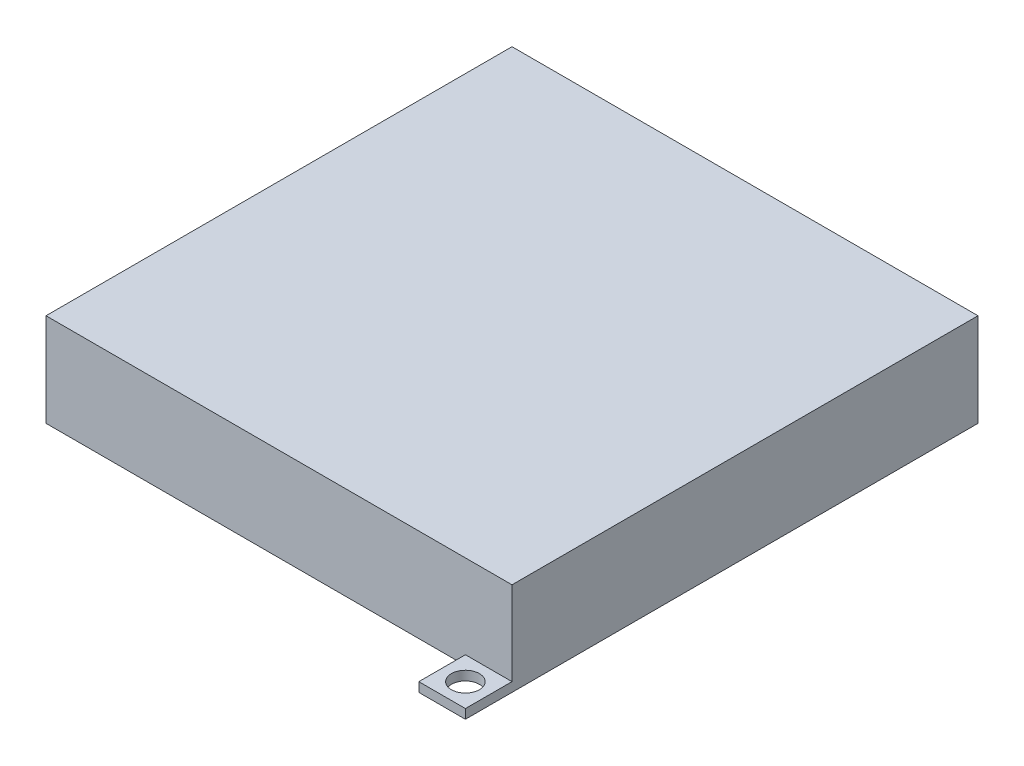
from build123d import *

# Parameters (mm, degrees)
SKETCH4_W           = 50
SKETCH4_H           = 50
BOSS_EXTRUDE1_DEPTH = 10
SKETCH5_W           = 40
SKETCH5_H           = 40
CUT_EXTRUDE1_DEPTH  = 7
SKETCH9_W           = 5
SKETCH9_H           = 5
SKETCH9_R           = 1.5
BOSS_EXTRUDE4_DEPTH = 1


with BuildPart() as part:
    # Sketch4 → Boss-Extrude1 (new body)
    with BuildSketch(Plane(origin=(0, 0, 0), x_dir=(1, 0, 0), z_dir=(0, 1, 0))):
        Rectangle(SKETCH4_W, SKETCH4_H)
    extrude(amount=BOSS_EXTRUDE1_DEPTH)

    # Sketch5 → Cut-Extrude1 (cut)
    with BuildSketch(Plane(origin=(0, 0, 0), x_dir=(1, 0, 0), z_dir=(0, 1, 0))):
        Rectangle(SKETCH5_W, SKETCH5_H)
    extrude(amount=CUT_EXTRUDE1_DEPTH, mode=Mode.SUBTRACT)

    # Sketch9 → Boss-Extrude4 (add)
    with BuildSketch(Plane.XZ):
        with Locations((-22.5, -27.5)):
            Rectangle(SKETCH9_W, SKETCH9_H)
        with Locations(Location((-22.5, -27.5, 0), (0, 0, 270))):  # turned: the seam where the file's is
            Circle(SKETCH9_R, mode=Mode.SUBTRACT)
        with Locations((22.5, 27.5)):
            Rectangle(SKETCH9_W, SKETCH9_H)
        with Locations(Location((22.5, 27.5, 0), (0, 0, 270))):  # turned: the seam where the file's is
            Circle(SKETCH9_R, mode=Mode.SUBTRACT)
    extrude(amount=-BOSS_EXTRUDE4_DEPTH)


solid = part.part
